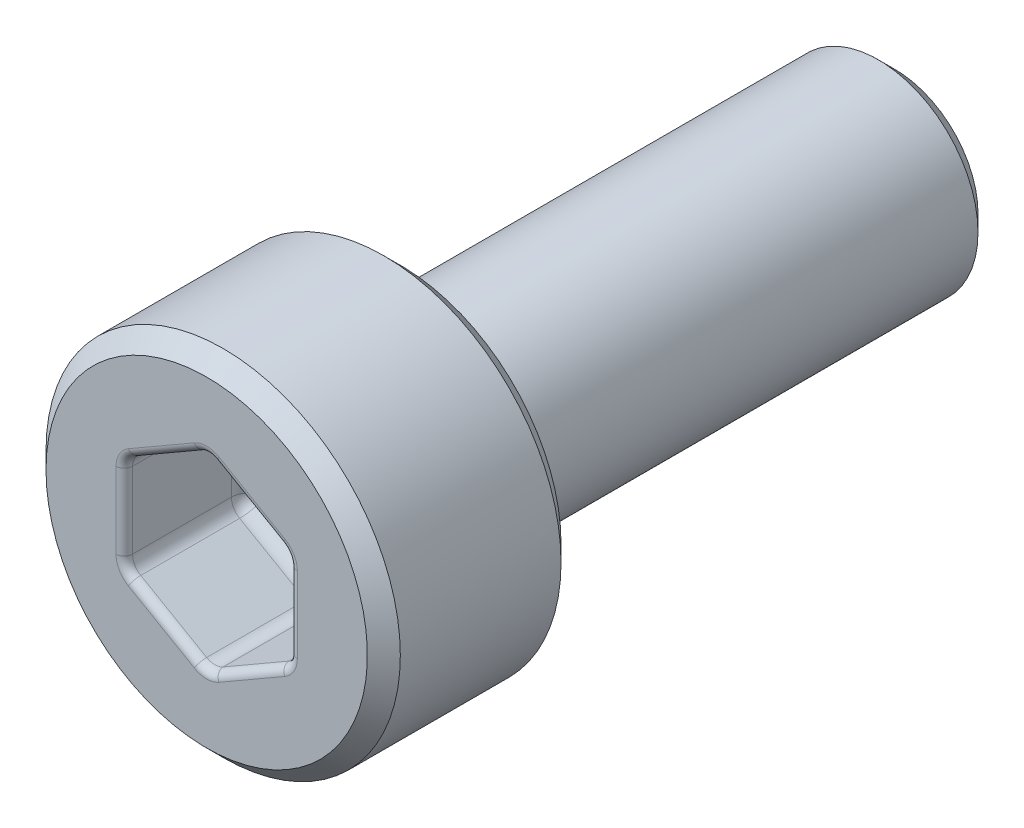
from build123d import *

# Parameters (mm, degrees)
SCHNITT_LINEAR_AUSTRAGEN1_DEPTH = 1.5
FASE1_SIZE                      = 0.2
VERRUNDUNG1_R                   = 0.2
VERRUNDUNG2_R                   = 0.1


with BuildPart() as part:
    # Skizze1 → Rotation1 (revolve)
    with BuildSketch(Plane(origin=(0, 0, 0), x_dir=(0, 0, -1), z_dir=(1, 0, 0))):
        Polygon((-2.35, 0), (-2.35, 2.15), (0, 2.15), (0, 1.21), (6, 1.21), (6, 0), align=None)
    revolve(axis=Axis((0, 0, 21.919879518), (0, 0, -1)))

    # Skizze2 → Schnitt-Linear austragen1 (cut)
    with BuildSketch(Plane.XY.offset(2.35)):
        Polygon((1, -0.577350269), (1, 0.577350269), (0, 1.154700538), (-1, 0.577350269), (-1, -0.577350269), (0, -1.154700538), align=None)
    extrude(amount=-SCHNITT_LINEAR_AUSTRAGEN1_DEPTH, mode=Mode.SUBTRACT)

    # Fase1
    fase1_edges = [part.edges().sort_by_distance(p)[0] for p in [
        (0, -2.15, 2.35),
        (0, -2.15, 0),
        (0, -1.21, -6),
    ]]
    chamfer(fase1_edges, length=FASE1_SIZE)

    # Verrundung1
    verrundung1_edges = [part.edges().sort_by_distance(p)[0] for p in [
        (-0.5, -0.866025404, 0.85),
        (-1, 0, 0.85),
        (-0.5, 0.866025404, 0.85),
        (0.5, 0.866025404, 0.85),
        (1, 0, 0.85),
        (0.5, -0.866025404, 0.85),
        (-1, -0.577350269, 1.6),
        (0, -1.154700538, 1.6),
        (1, -0.577350269, 1.6),
        (1, 0.577350269, 1.6),
        (0, 1.154700538, 1.6),
        (-1, 0.577350269, 1.6),
        (0, -1.21, 0),
    ]]
    fillet(verrundung1_edges, radius=VERRUNDUNG1_R)

    # Verrundung2
    verrundung2_edges = [part.edges().sort_by_distance(p)[0] for p in [
        (0.973205081, -0.561880215, 2.35),
        (0.5, -0.866025404, 2.35),
        (0, -1.123760431, 2.35),
        (-0.5, -0.866025404, 2.35),
        (-0.973205081, -0.561880215, 2.35),
        (-1, 0, 2.35),
        (-0.973205081, 0.561880215, 2.35),
        (-0.5, 0.866025404, 2.35),
        (0, 1.123760431, 2.35),
        (0.5, 0.866025404, 2.35),
        (0.973205081, 0.561880215, 2.35),
        (1, 0, 2.35),
    ]]
    fillet(verrundung2_edges, radius=VERRUNDUNG2_R)


solid = part.part
